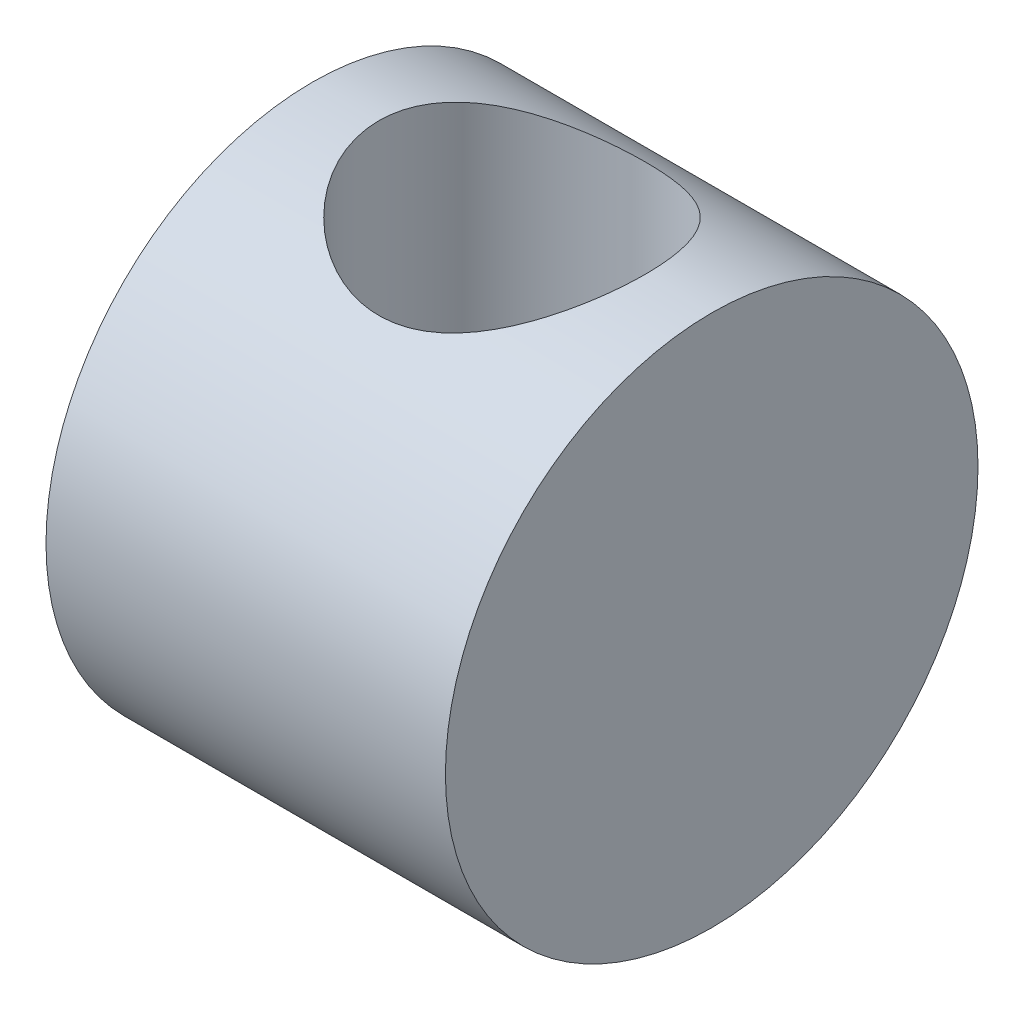
from build123d import *

# Parameters (mm, degrees)
SKETCH1_R               = 50
BOSS_EXTRUDE1_DEPTH     = 75
CUT_EXTRUDE1_DEPTH      = 100
CUT_EXTRUDE1_DEPTH_BACK = 100
SKETCH2_R               = 25


with BuildPart() as part:
    # Sketch1 → Boss-Extrude1 (new body)
    with BuildSketch(Plane(origin=(0, 0, 0), x_dir=(0, 0, -1), z_dir=(1, 0, 0))):
        Circle(SKETCH1_R)
    extrude(amount=BOSS_EXTRUDE1_DEPTH)

    # Sketch2 → Cut-Extrude1 (cut, two sides: drawn at the far end of the back side and taken through both)
    with BuildSketch(Plane(origin=(0, 0, 0), x_dir=(1, 0, 0), z_dir=(0, 1, 0)).offset(-CUT_EXTRUDE1_DEPTH_BACK)):
        with Locations((37.5, 0)):
            Circle(SKETCH2_R)
    extrude(amount=CUT_EXTRUDE1_DEPTH + CUT_EXTRUDE1_DEPTH_BACK, mode=Mode.SUBTRACT)


solid = part.part
